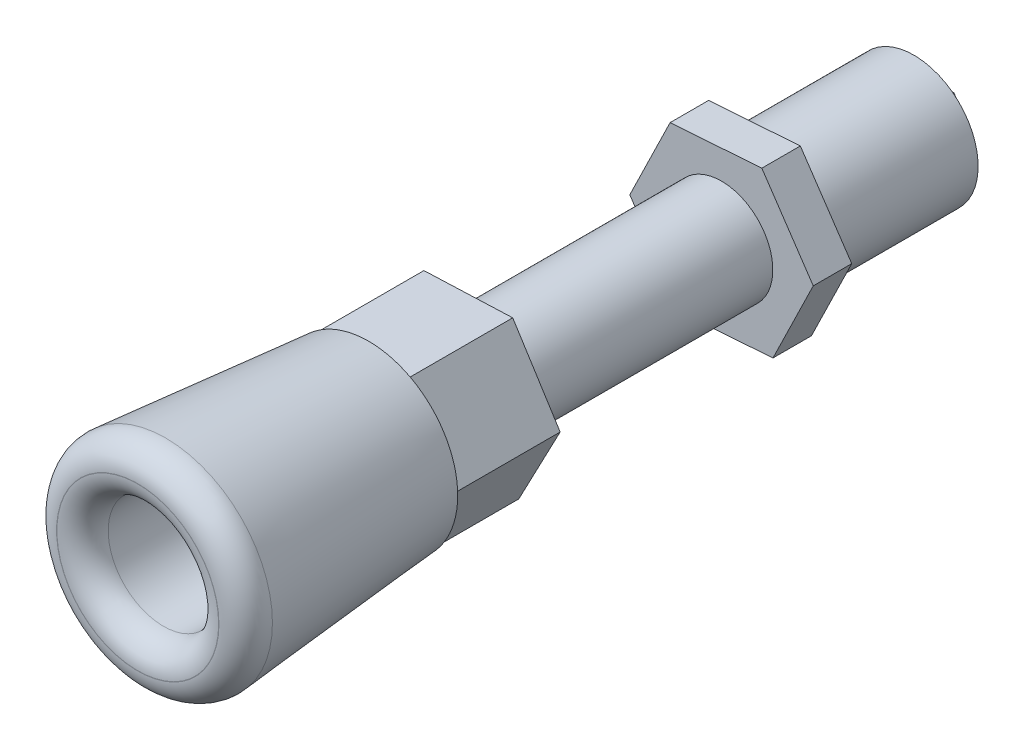
from build123d import *

# Parameters (mm, degrees)
EXTRUDE_1_DEPTH     = 8
SKETCH_2_R          = 4
EXTRUDE_2_DEPTH     = 19.5
EXTRUDE_3_DEPTH     = 3
SKETCH_4_R          = 5
EXTRUDE_4_DEPTH     = 12
EXTRUDE_5_DEPTH     = 2
SKETCH_10_R         = 6.937077861
EXTRUDE_6_DEPTH     = 18
EXTRUDE_6_TAPER     = -5
SKETCH_11_R         = 4.303815727
CUT_EXTRUDE_2_DEPTH = 18
SKETCH_12_R         = 1.731234863
CUT_EXTRUDE_3_DEPTH = 8
FILLET_1_R          = 2
SKETCH_13_R         = 0.923714742
CUT_EXTRUDE_4_DEPTH = 63.5


with BuildPart() as part:
    # 草图1 → 凸台-拉伸1 (new body)
    with BuildSketch(Plane.XY):
        Polygon((-3.698048527, 5.858706094), (-6.922812574, -0.273250922), (-3.224764047, -6.131957016), (3.698048527, -5.858706094), (6.922812574, 0.273250922), (3.224764047, 6.131957016), align=None)
    extrude(amount=EXTRUDE_1_DEPTH)

    # 草图2 → 凸台-拉伸2 (add)
    with BuildSketch(Plane(origin=(0, 0, 0), x_dir=(-1, 0, 0), z_dir=(0, 0, -1))):
        Circle(SKETCH_2_R)
    extrude(amount=EXTRUDE_2_DEPTH)

    # 草图3 → 凸台-拉伸3 (add)
    with BuildSketch(Plane(origin=(0, 0, -19.5), x_dir=(-1, 0, 0), z_dir=(0, 0, -1))):
        Polygon((4.007714345, 5.941327246), (-3.141483154, 6.441446057), (-7.149197499, 0.500118811), (-4.007714345, -5.941327246), (3.141483154, -6.441446057), (7.149197499, -0.500118811), align=None)
    extrude(amount=EXTRUDE_3_DEPTH)

    # 草图4 → 凸台-拉伸4 (add)
    with BuildSketch(Plane(origin=(0, 0, -22.5), x_dir=(-1, 0, 0), z_dir=(0, 0, -1))):
        Circle(SKETCH_4_R)
    extrude(amount=EXTRUDE_4_DEPTH)

    # 草图5 → 凸台-拉伸5 (add)
    with BuildSketch(Plane(origin=(0, 0, -34.5), x_dir=(-1, 0, 0), z_dir=(0, 0, -1))):
        Polygon((1.187065622, 1.98096152), (-1.122030189, 2.018509744), (-2.309095811, 0.037548225), (-1.187065622, -1.98096152), (1.122030189, -2.018509744), (2.309095811, -0.037548225), align=None)
    extrude(amount=EXTRUDE_5_DEPTH)

    # 草图10 → 凸台-拉伸6 (add)
    with BuildSketch(Plane.XY.offset(8)):
        Circle(SKETCH_10_R)
    extrude(amount=EXTRUDE_6_DEPTH, taper=EXTRUDE_6_TAPER)

    # 草图11 → 切除-拉伸2 (cut)
    with BuildSketch(Plane.XY.offset(26)):
        Circle(SKETCH_11_R)
    extrude(amount=-CUT_EXTRUDE_2_DEPTH, mode=Mode.SUBTRACT)

    # 草图12 → 切除-拉伸3 (cut)
    with BuildSketch(Plane.XY.offset(8)):
        Circle(SKETCH_12_R)
    extrude(amount=-CUT_EXTRUDE_3_DEPTH, mode=Mode.SUBTRACT)

    # 圆角1
    fillet_1_edges = [part.edges().sort_by_distance(p)[0] for p in [
        (-8.511873804, 0, 26),
        (-4.303815727, 0, 26),
    ]]
    fillet(fillet_1_edges, radius=FILLET_1_R)

    # 草图13 → 切除-拉伸4 (cut, through all)
    with BuildSketch(Plane(origin=(0, 0, -36.5), x_dir=(-1, 0, 0), z_dir=(0, 0, -1))):
        Circle(SKETCH_13_R)
    extrude(amount=-CUT_EXTRUDE_4_DEPTH, mode=Mode.SUBTRACT)


solid = part.part
